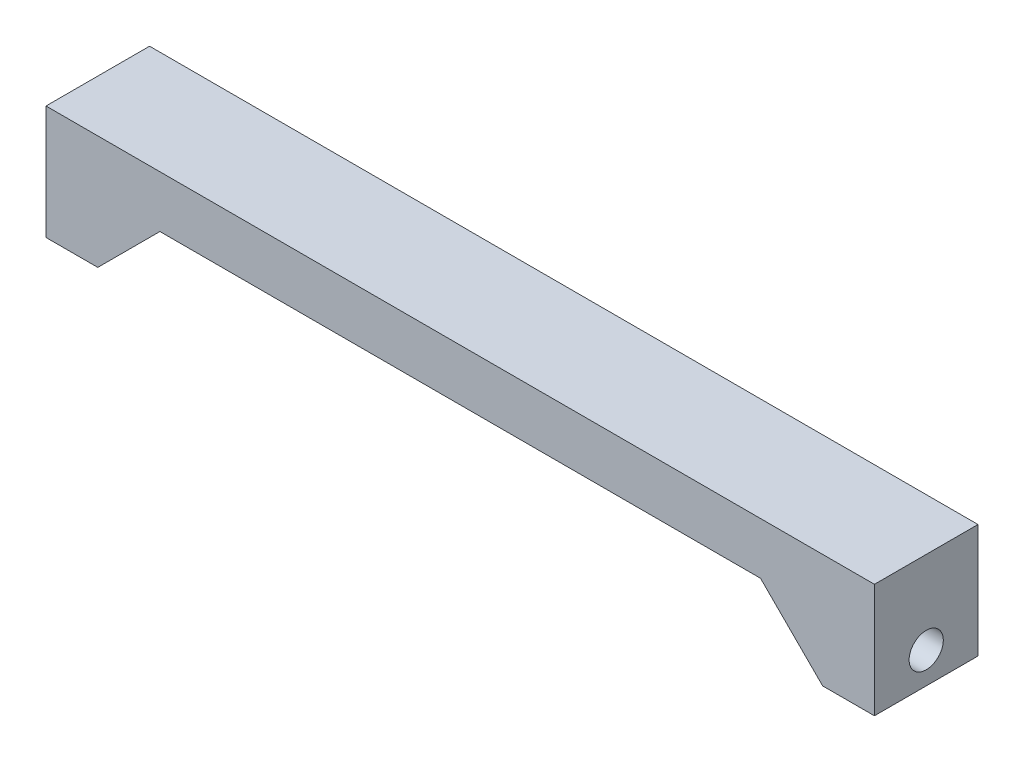
from build123d import *

# Parameters (mm, degrees)
EXTRUDE_2_DEPTH          = 10
SKETCH_3_R               = 1.65
CUT_EXTRUDE_1_DEPTH      = 76
CUT_EXTRUDE_1_DEPTH_BACK = 6
EXTRUDE_3_DEPTH          = 2
MIRROR_2_COPY_1_DEPTH    = 2


with BuildPart() as part:
    # 草图1 → 凸台-拉伸2 (new body)
    with BuildSketch(Plane.XY):
        Polygon((-40, 0), (40, 0), (40, -11), (35, -11), (35, -5), (-35, -5), (-35, -11), (-40, -11), align=None)
    extrude(amount=EXTRUDE_2_DEPTH)

    # 草图3 → 切除-拉伸1 (cut, two sides)
    with BuildSketch(Plane(origin=(-35, 0, 0), x_dir=(0, 0, -1), z_dir=(1, 0, 0))) as cut_extrude_1_sk:
        with Locations((-5, -8)):
            Circle(SKETCH_3_R)
    extrude(amount=CUT_EXTRUDE_1_DEPTH, mode=Mode.SUBTRACT)
    extrude(cut_extrude_1_sk.sketch, amount=-CUT_EXTRUDE_1_DEPTH_BACK, mode=Mode.SUBTRACT)

    # 草图4 → 凸台-拉伸3 (add)
    with BuildSketch(Plane(origin=(0, 0, 0), x_dir=(-1, 0, 0), z_dir=(0, 0, -1))):
        Polygon((29, -5), (35, -11), (35, -5), align=None)
    extrude_3 = extrude(amount=-EXTRUDE_3_DEPTH)

    # 镜向1: 凸台-拉伸3 across plane
    add(extrude_3.mirror(Plane.XY.offset(5)))

    # 镜向2: 凸台-拉伸3 across plane
    add(extrude_3.mirror(Plane(origin=(0, 0, 0), x_dir=(0, 0, 1), z_dir=(1, 0, 0))))

    # 镜向2 copy 1 sketch → 镜向2 copy 1 (add)
    with BuildSketch(Plane.XY.offset(10)):
        Polygon((29, -5), (35, -11), (35, -5), align=None)
    extrude(amount=-MIRROR_2_COPY_1_DEPTH)


solid = part.part
